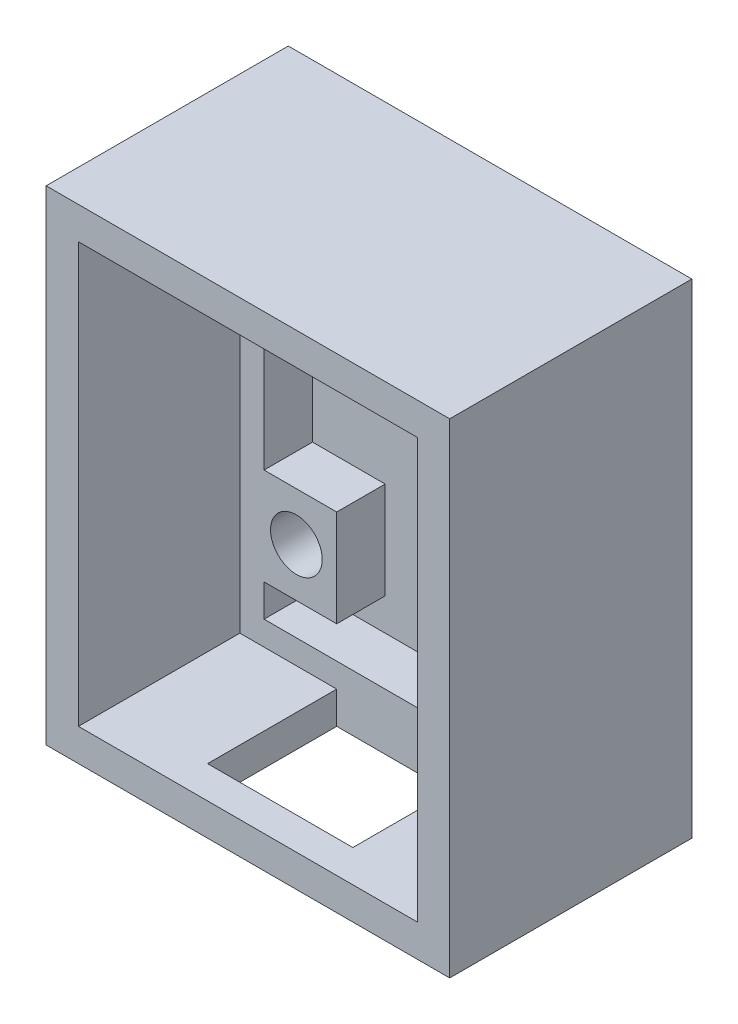
from build123d import *

# Parameters (mm, degrees)
SKETCH_1_W          = 25
SKETCH_1_H          = 30
EXTRUDE_1_DEPTH     = 15
SKETCH_2_W          = 21
SKETCH_2_H          = 26
CUT_EXTRUDE_1_DEPTH = 13
SKETCH_3_W          = 21
SKETCH_3_H          = 26
SKETCH_3_W_2        = 18
SKETCH_3_H_2        = 23
EXTRUDE_2_DEPTH     = 3
SKETCH_5_W          = 4.5
SKETCH_5_H          = 6
EXTRUDE_3_DEPTH     = 3
SKETCH_6_R          = 1.6
CUT_EXTRUDE_2_DEPTH = 6
SKETCH_7_W          = 9
SKETCH_7_H          = 8
CUT_EXTRUDE_3_DEPTH = 3


with BuildPart() as part:
    # ｽｹｯﾁ1 → ﾎﾞｽ - 押し出し1 (new body)
    with BuildSketch(Plane.XY):
        with Locations((-71.40312059, 25.678571429)):
            Rectangle(SKETCH_1_W, SKETCH_1_H)
    extrude(amount=EXTRUDE_1_DEPTH)

    # ｽｹｯﾁ2 → ｶｯﾄ - 押し出し1 (cut)
    with BuildSketch(Plane.XY.offset(15)):
        with Locations((-71.40312059, 25.678571429)):
            Rectangle(SKETCH_2_W, SKETCH_2_H)
    extrude(amount=-CUT_EXTRUDE_1_DEPTH, mode=Mode.SUBTRACT)

    # ｽｹｯﾁ3 → ﾎﾞｽ - 押し出し2 (add)
    with BuildSketch(Plane.XY.offset(2)):
        with Locations((-71.40312059, 25.678571429)):
            Rectangle(SKETCH_3_W, SKETCH_3_H)
        with Locations((-71.40312059, 25.678571429)):
            Rectangle(SKETCH_3_W_2, SKETCH_3_H_2, mode=Mode.SUBTRACT)
    extrude(amount=EXTRUDE_2_DEPTH)

    # ｽｹｯﾁ5 → ﾎﾞｽ - 押し出し3 (add)
    with BuildSketch(Plane.XY.offset(2)):
        with Locations((-64.65312059, 19.178571429)):
            Rectangle(SKETCH_5_W, SKETCH_5_H)
        with Locations((-78.15312059, 19.178571429)):
            Rectangle(SKETCH_5_W, SKETCH_5_H)
    extrude(amount=EXTRUDE_3_DEPTH)

    # ｽｹｯﾁ6 → ｶｯﾄ - 押し出し2 (cut, through all)
    with BuildSketch(Plane.XY.offset(5)):
        with Locations((-64.40312059, 19.178571429)):
            Circle(SKETCH_6_R)
        with Locations((-78.40312059, 19.178571429)):
            Circle(SKETCH_6_R)
    extrude(amount=-CUT_EXTRUDE_2_DEPTH, mode=Mode.SUBTRACT)

    # ｽｹｯﾁ7 → ｶｯﾄ - 押し出し3 (cut, through all)
    with BuildSketch(Plane(origin=(0, 12.678571429, 0), x_dir=(1, 0, 0), z_dir=(0, 1, 0))):
        with Locations((-71.40312059, -9)):
            Rectangle(SKETCH_7_W, SKETCH_7_H)
    extrude(amount=-CUT_EXTRUDE_3_DEPTH, mode=Mode.SUBTRACT)


solid = part.part
